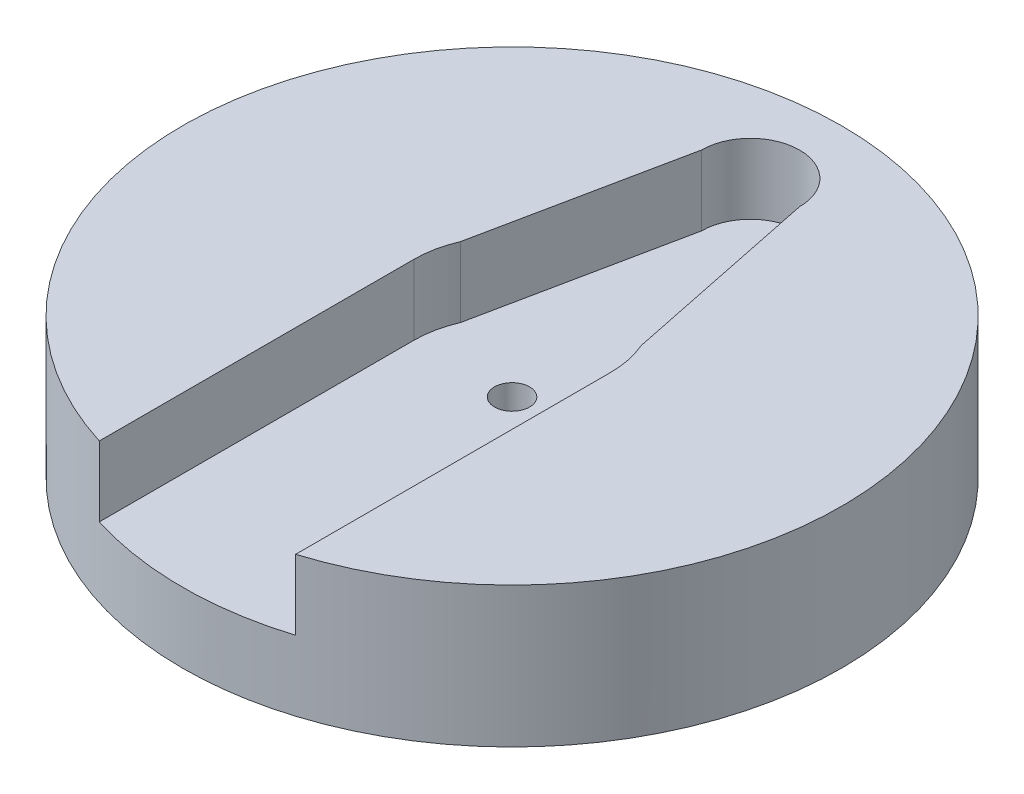
from build123d import *

# Parameters (mm, degrees)
CROQUIS1_R              = 23.5
SALIENTE_EXTRUIR1_DEPTH = 10
CORTAR_EXTRUIR3_DEPTH   = 5
CROQUIS3_R              = 1.25
CORTAR_EXTRUIR4_DEPTH   = 10
CORTAR_EXTRUIR6_DEPTH   = 2


with BuildPart() as part:
    # Croquis1 → Saliente-Extruir1 (new body)
    with BuildSketch(Plane(origin=(0, 0, 0), x_dir=(1, 0, 0), z_dir=(0, 1, 0))):
        Circle(CROQUIS1_R)
    extrude(amount=SALIENTE_EXTRUIR1_DEPTH)

    # Croquis2 → Cortar-Extruir3 (cut)
    with BuildSketch(Plane(origin=(0, 10, 0), x_dir=(1, 0, 0), z_dir=(0, 1, 0))):
        with BuildLine():
            ThreePointArc((3.5, 17), (0, 20.5), (-3.5, 17))
            Line((-3.5, 17), (3.5, 17))
        make_face()
        with BuildLine():
            Line((3.5, 17), (-3.5, 17))
            ThreePointArc((-3.5, 17), (0, 13.5), (3.5, 17))
        make_face()
        with BuildLine():
            Line((-3.5, 6.062177826), (-3.5, 17))
            Line((-3.5, 17), (-6.430705394, 2.765145228))
            ThreePointArc((-6.430705394, 2.765145228), (-5.231857547, 4.650555516), (-3.5, 6.062177826))
        make_face()
        with BuildLine():
            ThreePointArc((3.5, 17), (0, 13.5), (-3.5, 17))
            Line((-3.5, 17), (-3.5, 6.062177826))
            ThreePointArc((-3.5, 6.062177826), (0, 7), (3.5, 6.062177826))
            Line((3.5, 6.062177826), (3.5, 17))
        make_face()
        with BuildLine():
            Line((6.430705394, 2.765145228), (3.5, 17))
            Line((3.5, 17), (3.5, 6.062177826))
            ThreePointArc((3.5, 6.062177826), (5.231857547, 4.650555516), (6.430705394, 2.765145228))
        make_face()
        with BuildLine():
            ThreePointArc((6.430705394, 2.765145228), (5.231857547, 4.650555516), (3.5, 6.062177826))
            Line((3.5, 6.062177826), (3.5, 0))
            Line((3.5, 0), (7, 0))
            Line((7, 0), (6.430705394, 2.765145228))
        make_face()
        with BuildLine():
            ThreePointArc((3.5, 6.062177826), (0, 7), (-3.5, 6.062177826))
            Line((-3.5, 6.062177826), (-3.5, 0))
            Line((-3.5, 0), (3.5, 0))
            Line((3.5, 0), (3.5, 6.062177826))
        make_face()
        with BuildLine():
            Line((3.5, 0), (-3.5, 0))
            Line((-3.5, 0), (-3.5, -6.062177826))
            ThreePointArc((-3.5, -6.062177826), (0, -7), (3.5, -6.062177826))
            Line((3.5, -6.062177826), (3.5, 0))
        make_face()
        with BuildLine():
            ThreePointArc((-3.5, 6.062177826), (-5.231857547, 4.650555516), (-6.430705394, 2.765145228))
            Line((-6.430705394, 2.765145228), (-7, 0))
            Line((-7, 0), (-3.5, 0))
            Line((-3.5, 0), (-3.5, 6.062177826))
        make_face()
        with BuildLine():
            Line((-3.5, 0), (-7, 0))
            ThreePointArc((-7, 0), (-6.062177826, -3.5), (-3.5, -6.062177826))
            Line((-3.5, -6.062177826), (-3.5, 0))
        make_face()
        with BuildLine():
            Line((7, 0), (3.5, 0))
            Line((3.5, 0), (3.5, -6.062177826))
            ThreePointArc((3.5, -6.062177826), (6.062177826, -3.5), (7, 0))
        make_face()
        with BuildLine():
            ThreePointArc((7, 0), (6.856199303, 1.411570445), (6.430705394, 2.765145228))
            Line((6.430705394, 2.765145228), (7, 0))
        make_face()
        with BuildLine():
            Line((-7, 0), (-6.430705394, 2.765145228))
            ThreePointArc((-6.430705394, 2.765145228), (-6.856199303, 1.411570445), (-7, 0))
        make_face()
        with BuildLine():
            ThreePointArc((3.5, -6.062177826), (0, -7), (-3.5, -6.062177826))
            Line((-3.5, -6.062177826), (-3.5, -17))
            Line((-3.5, -17), (3.5, -17))
            Line((3.5, -17), (3.5, -6.062177826))
        make_face()
        with BuildLine():
            ThreePointArc((-3.5, -6.062177826), (-6.062177826, -3.5), (-7, 0))
            Line((-7, 0), (-7, -22.433234274))
            ThreePointArc((-7, -22.433234274), (-3.540409196, -23.231777864), (0, -23.5))
            ThreePointArc((0, -23.5), (3.540409196, -23.231777864), (7, -22.433234274))
            Line((7, -22.433234274), (7, 0))
            ThreePointArc((7, 0), (6.062177826, -3.5), (3.5, -6.062177826))
            Line((3.5, -6.062177826), (3.5, -17))
            Line((3.5, -17), (-3.5, -17))
            Line((-3.5, -17), (-3.5, -6.062177826))
        make_face()
    extrude(amount=-CORTAR_EXTRUIR3_DEPTH, mode=Mode.SUBTRACT)

    # Croquis3 → Cortar-Extruir4 (cut)
    with BuildSketch(Plane(origin=(0, 10, 0), x_dir=(1, 0, 0), z_dir=(0, 1, 0))):
        Circle(CROQUIS3_R)
    extrude(amount=-CORTAR_EXTRUIR4_DEPTH, mode=Mode.SUBTRACT)

    # Croquis5 → Cortar-Extruir6 (cut)
    with BuildSketch(Plane.XZ):
        with BuildLine():
            Line((-7.5, 2.5), (7.5, 2.5))
            ThreePointArc((7.5, 2.5), (10, 0), (7.5, -2.5))
            Line((7.5, -2.5), (-7.5, -2.5))
            ThreePointArc((-7.5, -2.5), (-10, 0), (-7.5, 2.5))
        make_face()
    extrude(amount=-CORTAR_EXTRUIR6_DEPTH, mode=Mode.SUBTRACT)


solid = part.part
